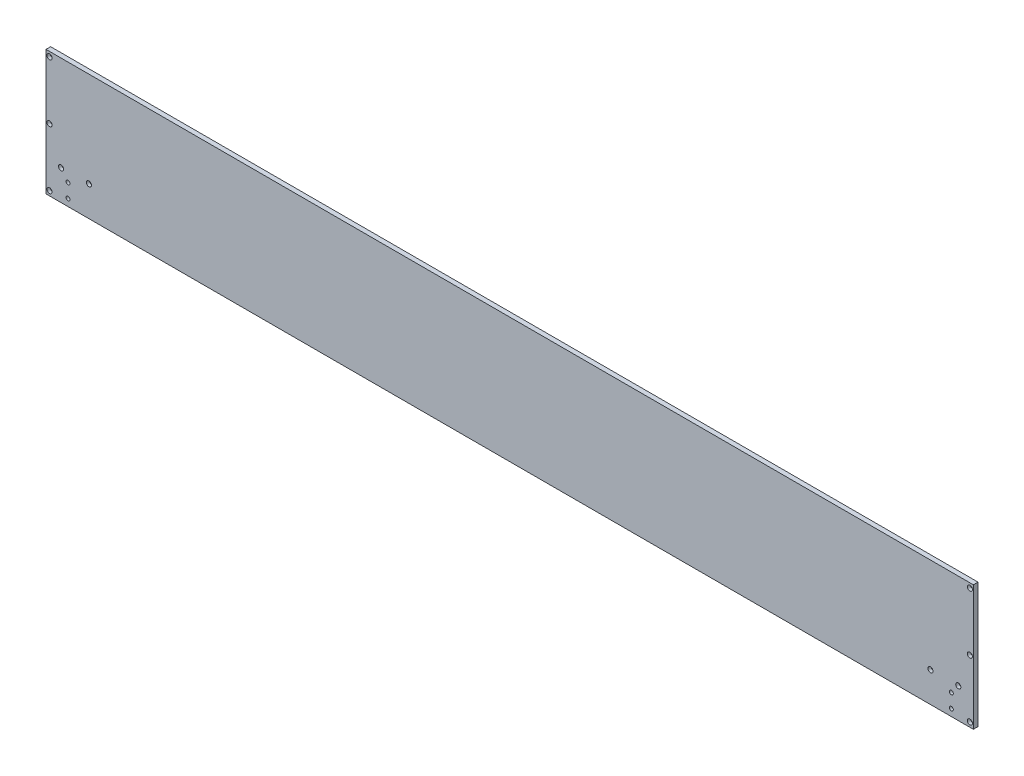
from build123d import *

# Parameters (mm, degrees)
SKETCH_1_W                = 2000
SKETCH_1_H                = 270
EXTRUDE_1_DEPTH           = 5
HOLE_WIZARD_1_D           = 6.6
HOLE_WIZARD_1_CBORE_D     = 11
HOLE_WIZARD_1_CBORE_DEPTH = 6.8
HOLE_WIZARD_M10_1_D       = 8.5
HOLE_WIZARD_2_D           = 6.6
HOLE_WIZARD_2_CBORE_D     = 11
HOLE_WIZARD_2_CBORE_DEPTH = 6.8


with BuildPart() as part:
    # 草图1 → 凸台-拉伸1 (new body, symmetric)
    with BuildSketch(Plane.XY):
        Rectangle(SKETCH_1_W, SKETCH_1_H)
    extrude(amount=EXTRUDE_1_DEPTH, both=True)

    # 打孔尺寸(%根据)内六角圆柱头螺钉的类型1 (through all)
    with Locations(Plane(origin=(-992.5, 125, 5), x_dir=(1, 0, 0), z_dir=(0, 0, 1))):
        with Locations((0, 0), (0, -250), (1985, 0), (1985, -250), (1985, -125), (0, -125)):
            CounterBoreHole(HOLE_WIZARD_1_D / 2, HOLE_WIZARD_1_CBORE_D / 2, HOLE_WIZARD_1_CBORE_DEPTH)

    # M10 螺纹孔1 (through all)
    with Locations(Plane(origin=(-952.5, -90, 5), x_dir=(1, 0, 0), z_dir=(0, 0, 1))):
        with Locations((0, 0), (0, -30)):
            hole_wizard_m10_1 = Hole(HOLE_WIZARD_M10_1_D / 2)

    # 镜向1: M10 螺纹孔1 across plane
    add(hole_wizard_m10_1.mirror(Plane(origin=(0, 0, 0), x_dir=(0, 0, 1), z_dir=(1, 0, 0))), mode=Mode.SUBTRACT)

    # 打孔尺寸(%根据)内六角圆柱头螺钉的类型2 (through all)
    with Locations(Plane(origin=(907.5, -70, 5), x_dir=(1, 0, 0), z_dir=(0, 0, 1))):
        with Locations((0, 0), (60, 0)):
            hole_wizard_2 = CounterBoreHole(HOLE_WIZARD_2_D / 2, HOLE_WIZARD_2_CBORE_D / 2, HOLE_WIZARD_2_CBORE_DEPTH)

    # 镜向2: 打孔尺寸(%根据)内六角圆柱头螺钉的类型2 across plane
    add(hole_wizard_2.mirror(Plane(origin=(0, 0, 0), x_dir=(0, 0, 1), z_dir=(1, 0, 0))), mode=Mode.SUBTRACT)


solid = part.part
